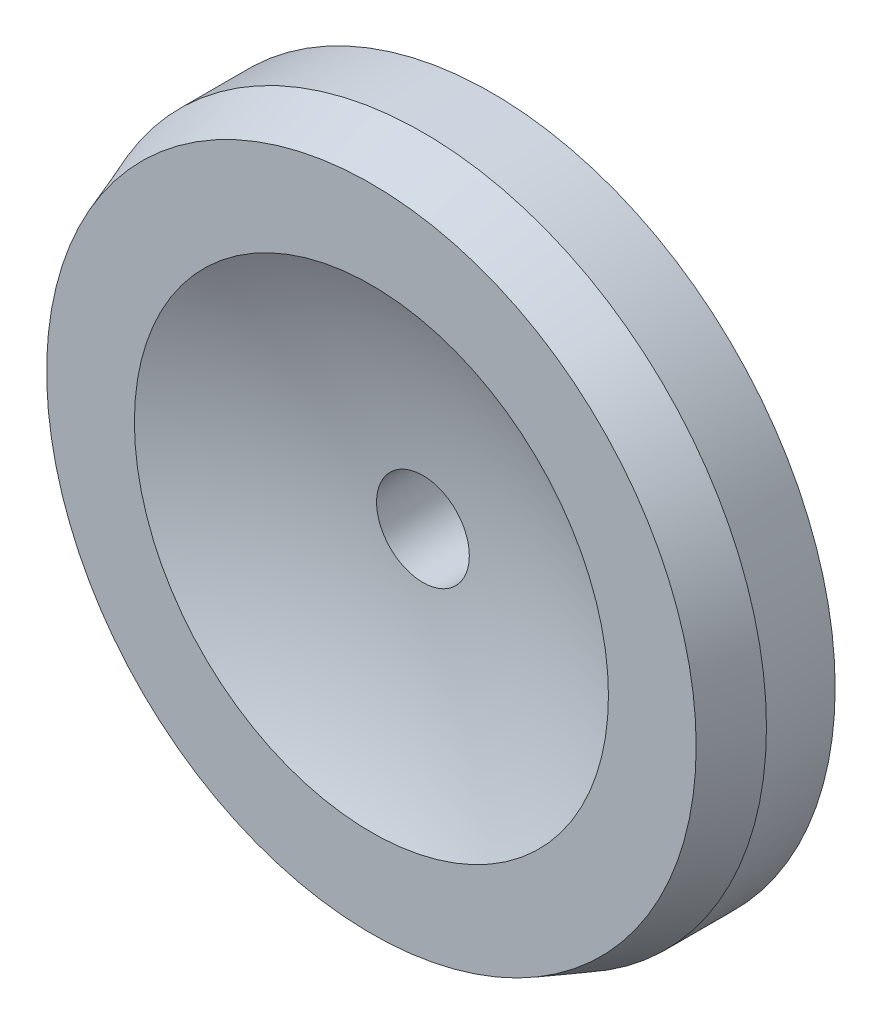
from build123d import *


with BuildPart() as part:
    # Sketch1 → Revolve1 (revolve)
    with BuildSketch(Plane(origin=(0, -10.25, 0), x_dir=(1, 0, 0), z_dir=(0, 1, 0))):
        with BuildLine():
            Line((1, -1.54), (1, -1.34))
            Line((1, -1.34), (0.135, -1.34))
            Line((0.135, -1.34), (0.135, -1.54))
            ThreePointArc((0.135, -1.54), (0.419262746, -1.589977841), (0.69, -1.69))
            Line((0.69, -1.69), (0.945404465, -1.69))
            Line((0.945404465, -1.69), (1, -1.54))
        make_face()
    revolve(axis=Axis((0, -10.25, 1.34), (0, 0, 1)))


solid = part.part
